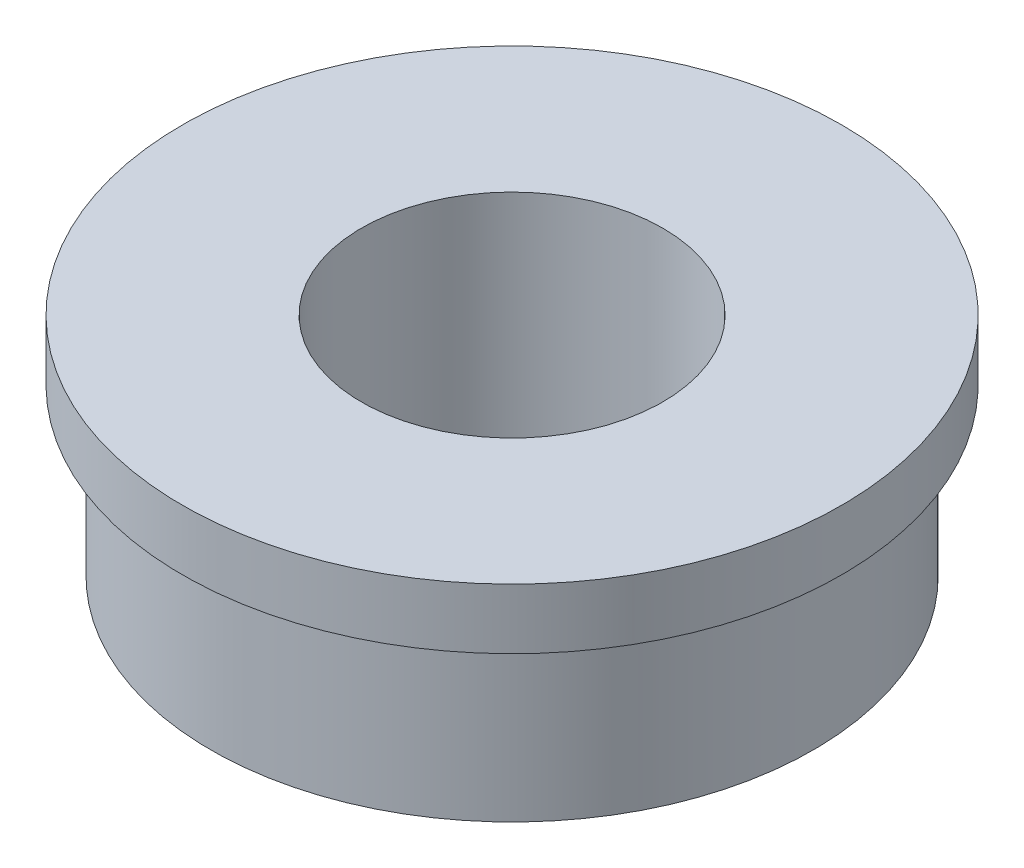
from build123d import *


with BuildPart() as part:
    # Sketch1 → Revolve1 (revolve)
    with BuildSketch(Plane(origin=(0, 0, 0), x_dir=(0, 0, -1), z_dir=(1, 0, 0))):
        Polygon((3.175, 0), (6.35, 0), (6.35, 3.4925), (6.9453125, 3.4925), (6.9453125, 4.7625), (3.175, 4.7625), align=None)
    revolve(axis=Axis((0, 0, 0), (0, 1, 0)))


solid = part.part
